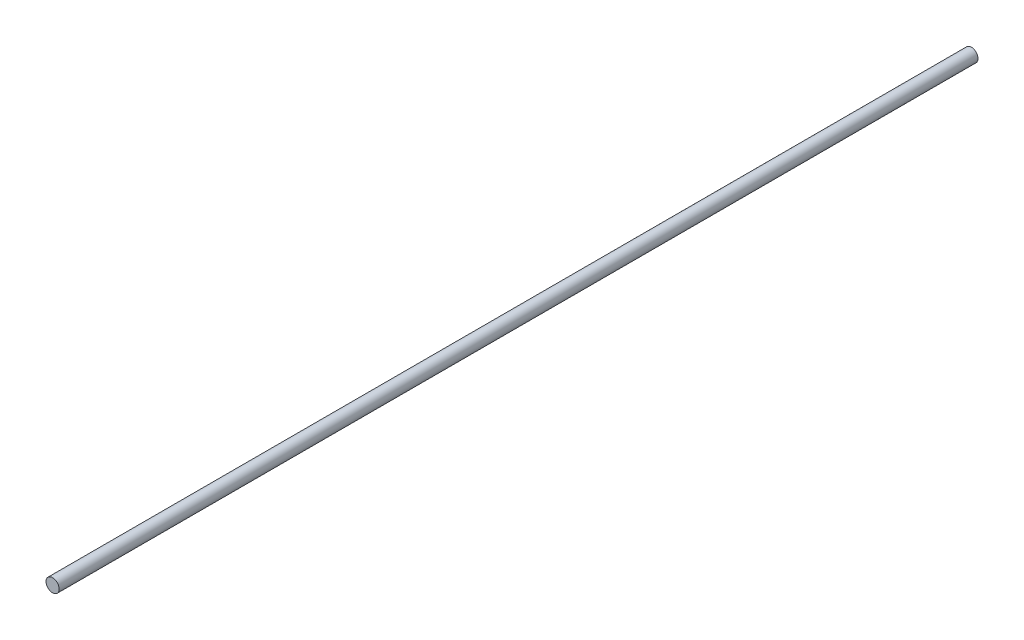
from build123d import *

# Parameters (mm, degrees)
SKETCH1_R           = 4
BOSS_EXTRUDE1_DEPTH = 558.8


with BuildPart() as part:
    # Sketch1 → Boss-Extrude1 (new body)
    with BuildSketch(Plane.XY):
        Circle(SKETCH1_R)
    extrude(amount=BOSS_EXTRUDE1_DEPTH)


solid = part.part
